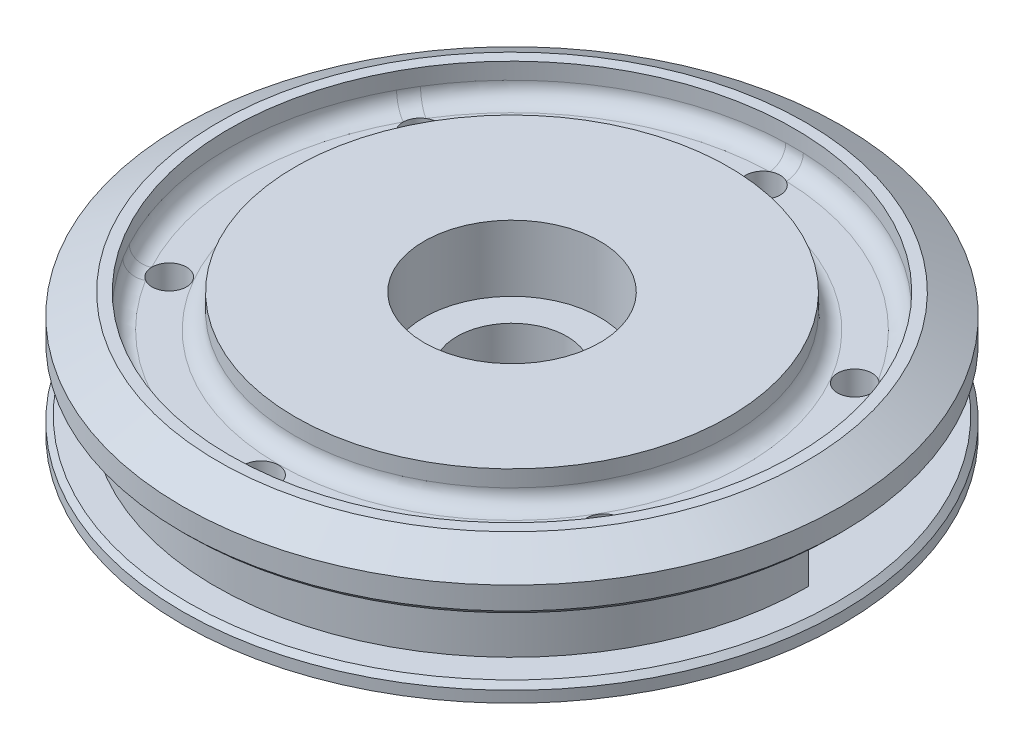
from build123d import *

# Parameters (mm, degrees)
F_10_24_TAPPED_HOLE1_D     = 3.7973
CHAMFER1_SIZE              = 0.762
SKETCH5_R                  = 7.9375
CUT_EXTRUDE2_DEPTH         = 25.7077
F_6_32_TAPPED_HOLE2_REACH  = 85.841
F_6_32_TAPPED_HOLE2_BORE_R = 1.35255
SKETCH12_R                 = 12.7
CUT_EXTRUDE3_DEPTH         = 9.525
CUT_EXTRUDE4_DEPTH         = 8.39875
F_6_32_TAPPED_HOLE1_D      = 2.7051
F_6_32_TAPPED_HOLE1_DEPTH  = 15
F_6_32_TAPPED_HOLE1_TIP    = 0.81269403
SKETCH18_R                 = 3.475
CUT_EXTRUDE6_DEPTH         = 1.778
F_10_CLEARANCE_HOLE1_D     = 4.9784
CIRPATTERN1_COUNT          = 6
CHAMFER2_SIZE              = 3
CHAMFER2_SIZE2             = 5.196152423
SKETCH23_R                 = 40.8305
SKETCH23_R_2               = 31.3055
CUT_EXTRUDE7_DEPTH         = 4.7625
FILLET1_R                  = 2.38125
FILLET2_R                  = 4.7625


with BuildPart() as part:
    # Sketch1 → Revolve1 (revolve)
    with BuildSketch(Plane.XY, mode=Mode.PRIVATE) as revolve1_sk:
        Polygon((0, 0), (11.1125, 0), (11.1125, 18.4277), (47.625, 18.4277), (47.625, 20.80895), (42.8625, 20.80895), (42.8625, 29.2077), (47.625, 29.2077), (47.625, 36.2077), (0, 36.2077), align=None)
    revolve(revolve1_sk.sketch.rotate(Axis((0, 36.2077, 0), (0, -1, 0)), 90), axis=Axis((0, 36.2077, 0), (0, -1, 0)))

    # #10-24 Tapped Hole1 (through all)
    with Locations(Plane(origin=(0, 36.2077, 0), x_dir=(1, 0, 0), z_dir=(0, 1, 0))):
        with Locations((0, 0)):
            Hole(F_10_24_TAPPED_HOLE1_D / 2)

    # Chamfer1
    chamfer1_edges = [part.edges().sort_by_distance(p)[0] for p in [
        (0, 29.2077, -47.625),
        (0, 20.80895, -47.625),
    ]]
    chamfer(chamfer1_edges, length=CHAMFER1_SIZE)

    # Sketch5 → Cut-Extrude2 (cut)
    with BuildSketch(Plane(origin=(0, 36.2077, 0), x_dir=(1, 0, 0), z_dir=(0, 1, 0))):
        with Locations(Location((0, 0, 0), (0, 0, 270))):
            Circle(SKETCH5_R)
    extrude(amount=-CUT_EXTRUDE2_DEPTH, mode=Mode.SUBTRACT)

    # #6-32 Tapped Hole2 bore → #6-32 Tapped Hole2 (cut, up to next)
    with BuildSketch(Plane(origin=(0, 0, -11.1125), x_dir=(-1, 0, 0), z_dir=(0, 0, -1)), mode=Mode.PRIVATE) as f_6_32_tapped_hole2_sk1:
        with Locations((0, 8.2677)):
            Circle(F_6_32_TAPPED_HOLE2_BORE_R)
    f_6_32_tapped_hole2_tool1 = extrude(f_6_32_tapped_hole2_sk1.sketch, amount=-F_6_32_TAPPED_HOLE2_REACH, mode=Mode.PRIVATE) & part.part
    add(f_6_32_tapped_hole2_tool1.solids().sort_by_distance((0, 8.2677, -11.1125))[0], mode=Mode.SUBTRACT)

    # Sketch12 → Cut-Extrude3 (cut)
    with BuildSketch(Plane(origin=(0, 36.2077, 0), x_dir=(1, 0, 0), z_dir=(0, 1, 0))):
        with Locations(Location((0, 0, 0), (0, 0, 270))):
            Circle(SKETCH12_R)
    extrude(amount=-CUT_EXTRUDE3_DEPTH, mode=Mode.SUBTRACT)

    # Sketch13 → Cut-Extrude4 (cut)
    with BuildSketch(Plane.XZ.offset(-29.2077)):
        with BuildLine():
            Line((36.5125, 0), (36.5125, -22.450640303))
            ThreePointArc((36.5125, -22.450640303), (41.244459855, -11.6656949), (42.8625, 0))
            Line((42.8625, 0), (36.5125, 0))
        make_face()
    extrude(amount=CUT_EXTRUDE4_DEPTH, mode=Mode.SUBTRACT)

    # #6-32 Tapped Hole1
    with Locations(Plane(origin=(36.5125, 0, 0), x_dir=(0, 0, -1), z_dir=(1, 0, 0))):
        with Locations((3.5, 25.008325)):
            Hole(F_6_32_TAPPED_HOLE1_D / 2, depth=F_6_32_TAPPED_HOLE1_DEPTH)
            with Locations((0, 0, -(F_6_32_TAPPED_HOLE1_DEPTH + F_6_32_TAPPED_HOLE1_TIP / 2))):  # 118° drill point
                Cone(0, F_6_32_TAPPED_HOLE1_D / 2, F_6_32_TAPPED_HOLE1_TIP, mode=Mode.SUBTRACT)

    # Sketch18 → Cut-Extrude6 (cut)
    with BuildSketch(Plane.XZ):
        with Locations(Location((0, 0, 0), (0, 0, 270))):
            Circle(SKETCH18_R)
    extrude(amount=-CUT_EXTRUDE6_DEPTH, mode=Mode.SUBTRACT)

    # #10 Clearance Hole1 (through all)
    with Locations(Plane(origin=(0, 18.4277, 0), x_dir=(-1, 0, 0), z_dir=(0, -1, 0))):
        with Locations((0, -36.2458)):
            f_10_clearance_hole1 = Hole(F_10_CLEARANCE_HOLE1_D / 2)

    # CirPattern1: #10 Clearance Hole1 ×6 about axis
    cirpattern1_axis = Axis((0, 0, 0), (0, 1, 0))
    for i in range(1, CIRPATTERN1_COUNT):
        add(f_10_clearance_hole1.rotate(cirpattern1_axis, i * 360 / CIRPATTERN1_COUNT), mode=Mode.SUBTRACT)

    # Chamfer2
    chamfer2_edges = [part.edges().sort_by_distance(p)[0] for p in [
        (0, 36.2077, -47.625),
    ]]
    chamfer2_side = [part.faces().sort_by_distance(p)[0] for p in [
        (0, 33.0887, -47.625),
    ]]
    chamfer(chamfer2_edges, length=CHAMFER2_SIZE, length2=CHAMFER2_SIZE2, reference=chamfer2_side[0])

    # Sketch23 → Cut-Extrude7 (cut)
    with BuildSketch(Plane(origin=(0, 36.2077, 0), x_dir=(1, 0, 0), z_dir=(0, 1, 0))):
        with Locations(Location((0, 0, 0), (0, 0, 270))):
            Circle(SKETCH23_R)
        with Locations(Location((0, 0, 0), (0, 0, 270))):
            Circle(SKETCH23_R_2, mode=Mode.SUBTRACT)
    extrude(amount=-CUT_EXTRUDE7_DEPTH, mode=Mode.SUBTRACT)

    # Fillet1
    fillet1_edges = [part.edges().sort_by_distance(p)[0] for p in [
        (0, 31.4452, -31.3055),
        (0, 31.4452, -40.8305),
    ]]
    fillet(fillet1_edges, radius=FILLET1_R)

    # Fillet2
    fillet2_edges = [part.edges().sort_by_distance(p)[0] for p in [
        (36.5125, 25.008325, -22.450640303),
    ]]
    fillet(fillet2_edges, radius=FILLET2_R)


solid = part.part
